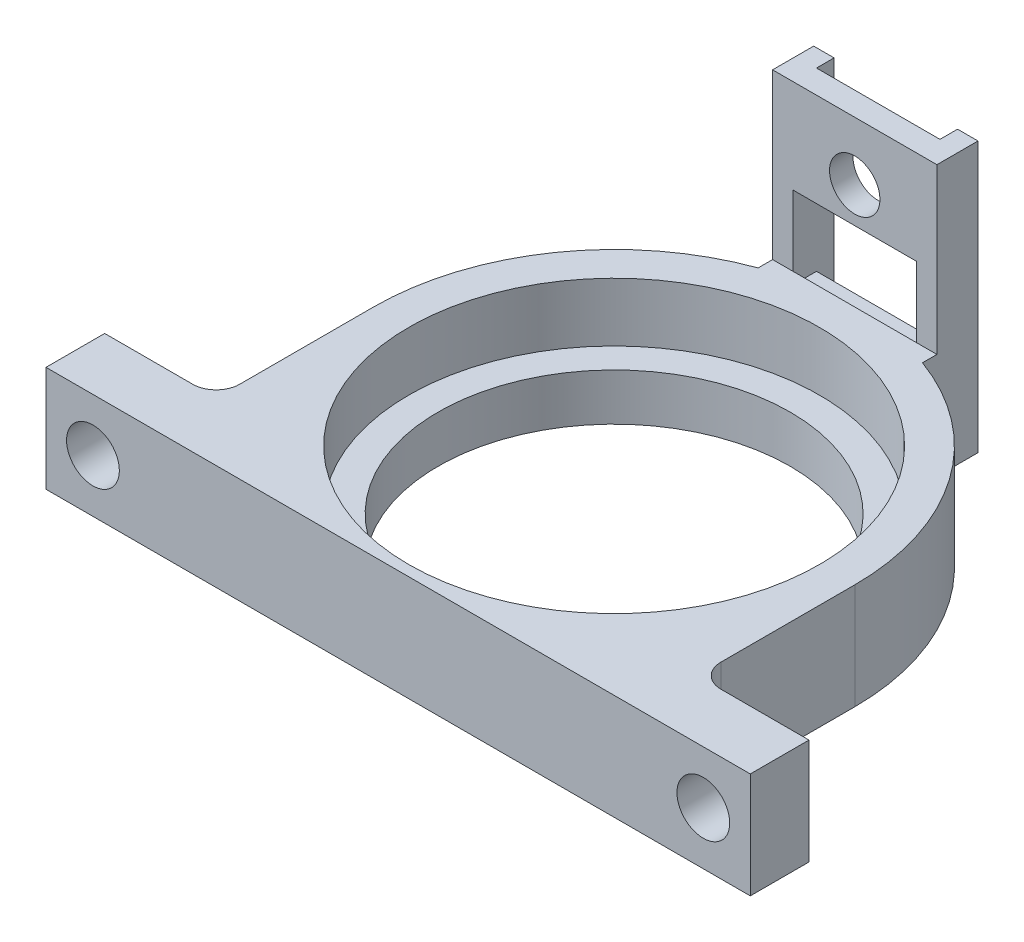
from build123d import *

# Parameters (mm, degrees)
SKETCH1_R                 = 17.5
BOSS_EXTRUDE1_DEPTH       = 5
SKETCH3_R                 = 15
BOSS_EXTRUDE2_DEPTH       = 4
FILLET2_R                 = 2
F_8_CLEARANCE_HOLE1_D     = 4.4958
F_8_CLEARANCE_HOLE1_DEPTH = 23.75
F_8_CLEARANCE_HOLE1_TIP   = 1.350674586
BOSS_EXTRUDE3_DEPTH       = 9
BOSS_EXTRUDE4_DEPTH       = 14
SKETCH8_R                 = 2.1463
CUT_EXTRUDE1_DEPTH        = 41.9
SKETCH9_W                 = 10.52
SKETCH9_H                 = 7
CUT_EXTRUDE2_DEPTH        = 2


with BuildPart() as part:
    # Sketch1 → Boss-Extrude1 (new body)
    with BuildSketch(Plane(origin=(0, 0, 0), x_dir=(1, 0, 0), z_dir=(0, 1, 0))):
        with BuildLine():
            ThreePointArc((-20.5, 18.4), (0, 38.9), (20.5, 18.4))
            Line((20.5, 18.4), (20.5, 5))
            Line((20.5, 5), (30, 5))
            Line((30, 5), (30, 0))
            Line((30, 0), (0, 0))
            Line((0, 0), (-30, 0))
            Line((-30, 0), (-30, 5))
            Line((-30, 5), (-20.5, 5))
            Line((-20.5, 5), (-20.5, 18.4))
        make_face()
        with Locations((0, 18.4)):
            Circle(SKETCH1_R, mode=Mode.SUBTRACT)
    extrude(amount=BOSS_EXTRUDE1_DEPTH)

    # Sketch3 → Boss-Extrude2 (add)
    with BuildSketch(Plane.XZ):
        with BuildLine():
            Line((20.5, -18.4), (20.5, -5))
            Line((20.5, -5), (30, -5))
            Line((30, -5), (30, 0))
            Line((30, 0), (-30, 0))
            Line((-30, 0), (-30, -5))
            Line((-30, -5), (-20.5, -5))
            Line((-20.5, -5), (-20.5, -18.4))
            ThreePointArc((-20.5, -18.4), (0, -38.9), (20.5, -18.4))
        make_face()
        with Locations((0, -18.4)):
            Circle(SKETCH3_R, mode=Mode.SUBTRACT)
    extrude(amount=BOSS_EXTRUDE2_DEPTH)

    # Fillet2
    fillet2_edges = [part.edges().sort_by_distance(p)[0] for p in [
        (20.5, 0.5, -5),
        (-20.5, 0.5, -5),
    ]]
    fillet(fillet2_edges, radius=FILLET2_R)

    # #8 Clearance Hole1
    with Locations(Plane(origin=(0, 0, -5), x_dir=(-1, 0, 0), z_dir=(0, 0, -1))):
        with Locations((-26, 0.5), (26, 0.5)):
            Hole(F_8_CLEARANCE_HOLE1_D / 2, depth=F_8_CLEARANCE_HOLE1_DEPTH)
            with Locations((0, 0, -(F_8_CLEARANCE_HOLE1_DEPTH + F_8_CLEARANCE_HOLE1_TIP / 2))):  # 118° drill point
                Cone(0, F_8_CLEARANCE_HOLE1_D / 2, F_8_CLEARANCE_HOLE1_TIP, mode=Mode.SUBTRACT)

    # Sketch6 → Boss-Extrude3 (add)
    with BuildSketch(Plane.XZ.offset(4)):
        with BuildLine():
            Line((7, -37.667848868), (7, -42.4))
            Line((7, -42.4), (5.26, -42.4))
            Line((5.26, -42.4), (5.26, -40.9))
            Line((5.26, -40.9), (-5.26, -40.9))
            Line((-5.26, -40.9), (-5.26, -42.4))
            Line((-5.26, -42.4), (-7, -42.4))
            Line((-7, -42.4), (-7, -37.667848868))
            ThreePointArc((-7, -37.667848868), (0, -38.9), (7, -37.667848868))
        make_face()
    extrude(amount=-BOSS_EXTRUDE3_DEPTH)

    # Sketch7 → Boss-Extrude4 (add)
    with BuildSketch(Plane(origin=(0, 5, 0), x_dir=(1, 0, 0), z_dir=(0, 1, 0))):
        Polygon((5.26, 42.4), (7, 42.4), (7, 38.9), (-7, 38.9), (-7, 42.4), (-5.26, 42.4), (-5.26, 40.9), (5.26, 40.9), align=None)
    extrude(amount=BOSS_EXTRUDE4_DEPTH)

    # Sketch8 → Cut-Extrude1 (cut, through all)
    with BuildSketch(Plane(origin=(0, 0, -40.9), x_dir=(-1, 0, 0), z_dir=(0, 0, -1))):
        with Locations((0, 14)):
            Circle(SKETCH8_R)
    extrude(amount=-CUT_EXTRUDE1_DEPTH, mode=Mode.SUBTRACT)

    # Sketch9 → Cut-Extrude2 (cut)
    with BuildSketch(Plane(origin=(0, 0, -40.9), x_dir=(-1, 0, 0), z_dir=(0, 0, -1))):
        with Locations((0, 7.5)):
            Rectangle(SKETCH9_W, SKETCH9_H)
    extrude(amount=-CUT_EXTRUDE2_DEPTH, mode=Mode.SUBTRACT)


solid = part.part
